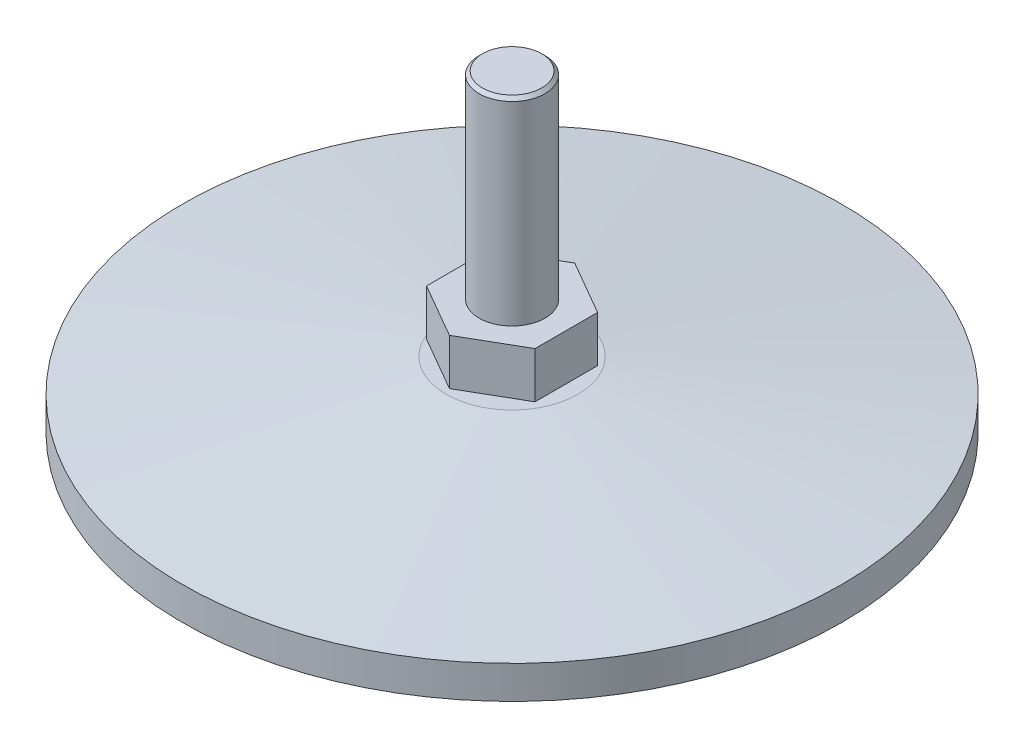
from build123d import *

# Parameters (mm, degrees)
CHAMFER_1_SIZE      = 0.5
CUT_EXTRUDE_START   = -7
SKETCH_2_R          = 12.139773641
CUT_EXTRUDE_1_DEPTH = 7


with BuildPart() as part:
    # Эскиз1 → Повернуть1 (revolve)
    with BuildSketch(Plane.XY, mode=Mode.PRIVATE) as revolve_1_sk:
        Polygon((0, 47.5), (-5, 47.5), (-5, 17.5), (-9.5, 17.5), (-9.5, 10.5), (-5, 10.5), (-5, 10), (-10, 10), (-50, 5), (-50, 0), (-5, 0), (-5, 7), (0, 7), align=None)
    revolve(revolve_1_sk.sketch.rotate(Axis((0, 0, 0), (0, 1, 0)), 180), axis=Axis((0, 0, 0), (0, 1, 0)))  # turned: the seam where the file's is

    # Фаска1
    chamfer_1_edges = [part.edges().sort_by_distance(p)[0] for p in [
        (-5, 47.5, 0),
    ]]
    chamfer(chamfer_1_edges, length=CHAMFER_1_SIZE)

    # Эскиз2 → Вырез-Вытянуть1 (cut)
    with BuildSketch(Plane(origin=(0, 17.5, 0), x_dir=(1, 0, 0), z_dir=(0, 1, 0)).offset(CUT_EXTRUDE_START)):
        Circle(SKETCH_2_R)
        Polygon((0, 9.5), (-8.227241336, 4.75), (-8.227241336, -4.75), (0, -9.5), (8.227241336, -4.75), (8.227241336, 4.75), align=None, mode=Mode.SUBTRACT)
    extrude(amount=CUT_EXTRUDE_1_DEPTH, mode=Mode.SUBTRACT)


solid = part.part
